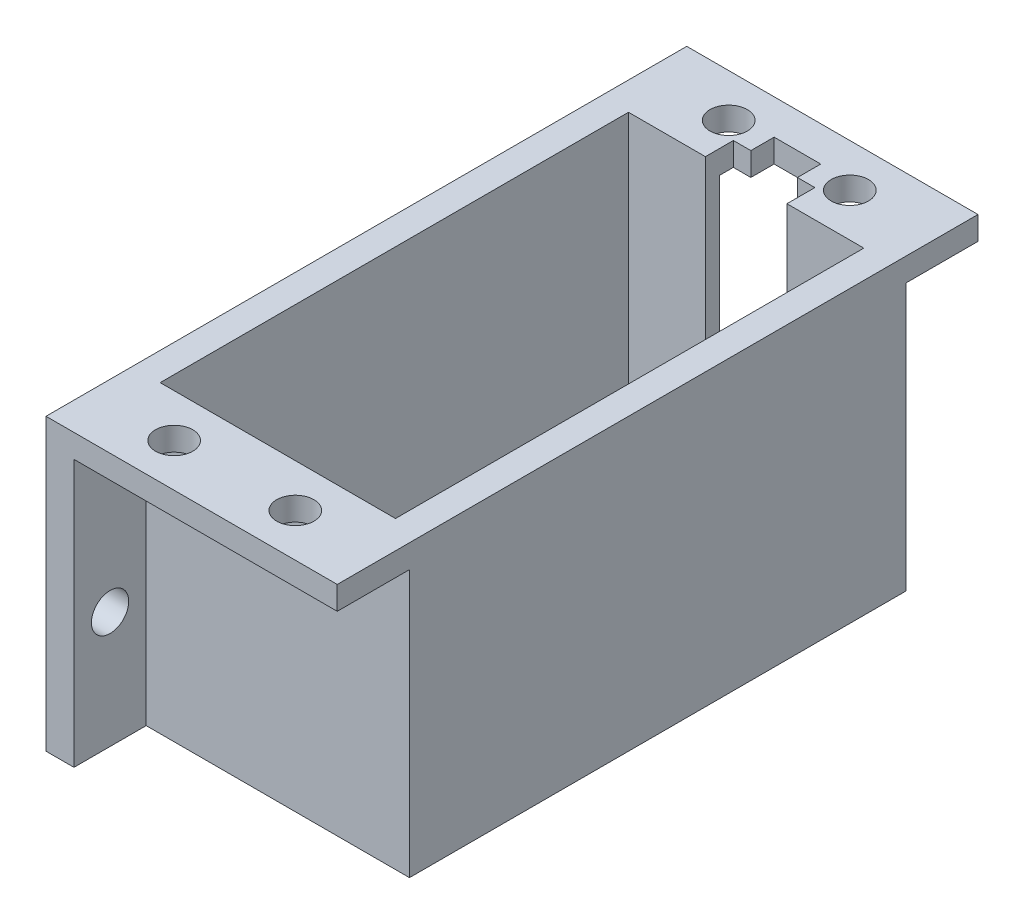
from build123d import *

# Parameters (mm, degrees)
SKETCH2_W           = 75
SKETCH2_H           = 8
SKETCH2_R           = 1.6
BOSS_EXTRUDE1_DEPTH = 2
SKETCH3_W           = 25
SKETCH3_H           = 18.5
BOSS_EXTRUDE2_DEPTH = 2
SKETCH4_W           = 25
SKETCH4_H           = 2
BOSS_EXTRUDE3_DEPTH = 18.5
SKETCH5_W           = 10.2
SKETCH5_H           = 40.2
CUT_EXTRUDE1_DEPTH  = 18.5
SKETCH6_W           = 10.2
SKETCH6_H           = 40.2
BOSS_EXTRUDE4_DEPTH = 24.9
SKETCH8_W           = 25
SKETCH8_H           = 7
BOSS_EXTRUDE5_DEPTH = 2
SKETCH9_R           = 1.6
CUT_EXTRUDE2_DEPTH  = 2
SKETCH10_W          = 20.2
SKETCH10_H          = 40.2
CUT_EXTRUDE3_DEPTH  = 77
SKETCH11_W          = 7
SKETCH11_H          = 2.4
CUT_EXTRUDE4_DEPTH  = 77
SKETCH12_W          = 2.4
SKETCH12_H          = 7
BOSS_EXTRUDE6_DEPTH = 24.9
SKETCH13_W          = 4
SKETCH13_H          = 4
CUT_EXTRUDE5_DEPTH  = 77
SKETCH14_W          = 25
SKETCH14_H          = 8
SKETCH14_R          = 1.6
BOSS_EXTRUDE7_DEPTH = 2
CUT_EXTRUDE6_DEPTH  = 2
CHAMFER1_SIZE       = 10
CUT_EXTRUDE7_DEPTH  = 1.2
SKETCH17_W          = 20.2
SKETCH17_H          = 22.9
CUT_EXTRUDE8_DEPTH  = 1.2
CUT_EXTRUDE9_DEPTH  = 2
CUT_EXTRUDE10_DEPTH = 2
SKETCH20_W          = 25
SKETCH20_H          = 8
CUT_EXTRUDE11_DEPTH = 156
SKETCH21_W          = 6.2
SKETCH21_H          = 22.9
CUT_EXTRUDE12_DEPTH = 55
SKETCH22_R          = 1.6
CUT_EXTRUDE13_DEPTH = 55


with BuildPart() as part:
    # Sketch2 → Boss-Extrude1 (new body)
    with BuildSketch(Plane(origin=(0, 0, 0), x_dir=(1, 0, 0), z_dir=(0, 1, 0))):
        Rectangle(SKETCH2_W, SKETCH2_H)
        with Locations((-31.75, 0)):
            Circle(SKETCH2_R, mode=Mode.SUBTRACT)
        with Locations((31.75, 0)):
            Circle(SKETCH2_R, mode=Mode.SUBTRACT)
    extrude(amount=BOSS_EXTRUDE1_DEPTH)

    # Sketch3 → Boss-Extrude2 (add)
    with BuildSketch(Plane(origin=(0, 2, 0), x_dir=(1, 0, 0), z_dir=(0, 1, 0))):
        with Locations((0, -13.25)):
            Rectangle(SKETCH3_W, SKETCH3_H)
    extrude(amount=-BOSS_EXTRUDE2_DEPTH)

    # Sketch4 → Boss-Extrude3 (add)
    with BuildSketch(Plane(origin=(0, 0, -4), x_dir=(-1, 0, 0), z_dir=(0, 0, -1))):
        with Locations((0, 1)):
            Rectangle(SKETCH4_W, SKETCH4_H)
    extrude(amount=BOSS_EXTRUDE3_DEPTH)

    # Sketch5 → Cut-Extrude1 (cut)
    with BuildSketch(Plane(origin=(0, 2, 0), x_dir=(1, 0, 0), z_dir=(0, 1, 0))):
        Rectangle(SKETCH5_W, SKETCH5_H)
    extrude(amount=-CUT_EXTRUDE1_DEPTH, mode=Mode.SUBTRACT)

    # Sketch6 → Boss-Extrude4 (add)
    with BuildSketch(Plane(origin=(0, 2, 0), x_dir=(1, 0, 0), z_dir=(0, 1, 0))):
        Polygon((-12.5, 4), (-12.5, -4), (-12.5, -22.5), (12.5, -22.5), (12.5, -4), (12.5, 4), (12.5, 22.5), (-12.5, 22.5), align=None)
        Rectangle(SKETCH6_W, SKETCH6_H, mode=Mode.SUBTRACT)
    extrude(amount=BOSS_EXTRUDE4_DEPTH)

    # Sketch8 → Boss-Extrude5 (add)
    with BuildSketch(Plane(origin=(0, 26.9, 0), x_dir=(1, 0, 0), z_dir=(0, 1, 0))):
        with Locations((0, 26)):
            Rectangle(SKETCH8_W, SKETCH8_H)
        with Locations((0, -26)):
            Rectangle(SKETCH8_W, SKETCH8_H)
    extrude(amount=-BOSS_EXTRUDE5_DEPTH)

    # Sketch9 → Cut-Extrude2 (cut)
    with BuildSketch(Plane.XZ.offset(-24.9)):
        with Locations((5.2, 23.8)):
            Circle(SKETCH9_R)
        with Locations((-5.2, 23.8)):
            Circle(SKETCH9_R)
        with Locations((-5.2, -23.8)):
            Circle(SKETCH9_R)
        with Locations((5.2, -23.8)):
            Circle(SKETCH9_R)
    extrude(amount=-CUT_EXTRUDE2_DEPTH, mode=Mode.SUBTRACT)

    # Sketch10 → Cut-Extrude3 (cut)
    with BuildSketch(Plane.XZ):
        Rectangle(SKETCH10_W, SKETCH10_H)
    extrude(amount=-CUT_EXTRUDE3_DEPTH, mode=Mode.SUBTRACT)

    # Sketch11 → Cut-Extrude4 (cut)
    with BuildSketch(Plane.XZ):
        with Locations((0, -21.3)):
            Rectangle(SKETCH11_W, SKETCH11_H)
    extrude(amount=-CUT_EXTRUDE4_DEPTH, mode=Mode.SUBTRACT)

    # Sketch12 → Boss-Extrude6 (add)
    with BuildSketch(Plane.XZ):
        with Locations((-11.3, 26)):
            Rectangle(SKETCH12_W, SKETCH12_H)
        with Locations((-11.3, -26)):
            Rectangle(SKETCH12_W, SKETCH12_H)
        with Locations((11.3, 26)):
            Rectangle(SKETCH12_W, SKETCH12_H)
        with Locations((11.3, -26)):
            Rectangle(SKETCH12_W, SKETCH12_H)
    extrude(amount=-BOSS_EXTRUDE6_DEPTH)

    # Sketch13 → Cut-Extrude5 (cut)
    with BuildSketch(Plane(origin=(0, 26.9, 0), x_dir=(1, 0, 0), z_dir=(0, 1, 0))):
        with Locations((0, 22.5)):
            Rectangle(SKETCH13_W, SKETCH13_H)
    extrude(amount=-CUT_EXTRUDE5_DEPTH, mode=Mode.SUBTRACT)

    # Sketch14 → Boss-Extrude7 (add)
    with BuildSketch(Plane(origin=(0, 2, 0), x_dir=(1, 0, 0), z_dir=(0, 1, 0))):
        with Locations((-25, 0)):
            Rectangle(SKETCH14_W, SKETCH14_H)
        with Locations((-31.75, 0)):
            Circle(SKETCH14_R, mode=Mode.SUBTRACT)
        with Locations((25, 0)):
            Rectangle(SKETCH14_W, SKETCH14_H)
        with Locations((31.75, 0)):
            Circle(SKETCH14_R, mode=Mode.SUBTRACT)
    extrude(amount=BOSS_EXTRUDE7_DEPTH)

    # Sketch15 → Cut-Extrude6 (cut)
    with BuildSketch(Plane.XZ):
        Polygon((10.1, -20.1), (3.5, -20.1), (3.5, -22.5), (10.1, -22.5), (10.1, -29.5), (12.5, -29.5), (12.5, -4), (37.5, -4), (37.5, 4), (12.5, 4), (12.5, 29.5), (10.1, 29.5), (10.1, 22.5), (-10.1, 22.5), (-10.1, 29.5), (-12.5, 29.5), (-12.5, 4), (-37.5, 4), (-37.5, -4), (-12.5, -4), (-12.5, -29.5), (-10.1, -29.5), (-10.1, -22.5), (-3.5, -22.5), (-3.5, -20.1), (-10.1, -20.1), (-10.1, 20.1), (10.1, 20.1), align=None)
    extrude(amount=-CUT_EXTRUDE6_DEPTH, mode=Mode.SUBTRACT)

    # Chamfer1
    chamfer1_edges = [part.edges().sort_by_distance(p)[0] for p in [
        (-12.5, 4, 0),
        (12.5, 4, 0),
    ]]
    chamfer(chamfer1_edges, length=CHAMFER1_SIZE)

    # Sketch16 → Cut-Extrude7 (cut)
    with BuildSketch(Plane.XY.offset(22.5)):
        Polygon((-10.1, 2), (10.1, 2), (10.1, 24.9), (6.132737905, 24.9), (4.267262095, 24.9), (-4.267262095, 24.9), (-6.132737905, 24.9), (-10.1, 24.9), align=None)
    extrude(amount=-CUT_EXTRUDE7_DEPTH, mode=Mode.SUBTRACT)

    # Sketch17 → Cut-Extrude8 (cut)
    with BuildSketch(Plane(origin=(0, 0, -22.5), x_dir=(-1, 0, 0), z_dir=(0, 0, -1))):
        with Locations((0, 13.45)):
            Rectangle(SKETCH17_W, SKETCH17_H)
    extrude(amount=-CUT_EXTRUDE8_DEPTH, mode=Mode.SUBTRACT)

    # Sketch18 → Cut-Extrude9 (cut)
    with BuildSketch(Plane(origin=(0, 0, -29.5), x_dir=(-1, 0, 0), z_dir=(0, 0, -1))):
        Polygon((10.1, 2), (12.5, 2), (12.5, 26.9), (-12.5, 26.9), (-12.5, 2), (-10.1, 2), (-10.1, 24.9), (10.1, 24.9), align=None)
    extrude(amount=-CUT_EXTRUDE9_DEPTH, mode=Mode.SUBTRACT)

    # Sketch19 → Cut-Extrude10 (cut)
    with BuildSketch(Plane.XY.offset(29.5)):
        Polygon((10.1, 2), (12.5, 2), (12.5, 26.9), (-12.5, 26.9), (-12.5, 2), (-10.1, 2), (-10.1, 24.9), (10.1, 24.9), align=None)
    extrude(amount=-CUT_EXTRUDE10_DEPTH, mode=Mode.SUBTRACT)

    # Sketch20 → Cut-Extrude11 (cut)
    with BuildSketch(Plane.XZ.offset(-2)):
        with Locations((-25, 0)):
            Rectangle(SKETCH20_W, SKETCH20_H)
        with Locations((25, 0)):
            Rectangle(SKETCH20_W, SKETCH20_H)
    extrude(amount=-CUT_EXTRUDE11_DEPTH, mode=Mode.SUBTRACT)

    # Sketch21 → Cut-Extrude12 (cut)
    with BuildSketch(Plane(origin=(-10.1, 0, 0), x_dir=(0, 0, -1), z_dir=(1, 0, 0))):
        with Locations((-24.4, 13.45)):
            Rectangle(SKETCH21_W, SKETCH21_H)
        with Locations((24.4, 13.45)):
            Rectangle(SKETCH21_W, SKETCH21_H)
    extrude(amount=CUT_EXTRUDE12_DEPTH, mode=Mode.SUBTRACT)

    # Sketch22 → Cut-Extrude13 (cut)
    with BuildSketch(Plane(origin=(-10.1, 0, 0), x_dir=(0, 0, -1), z_dir=(1, 0, 0))):
        with Locations((-24.4, 12)):
            Circle(SKETCH22_R)
        with Locations((24.4, 12)):
            Circle(SKETCH22_R)
    extrude(amount=-CUT_EXTRUDE13_DEPTH, mode=Mode.SUBTRACT)


solid = part.part
